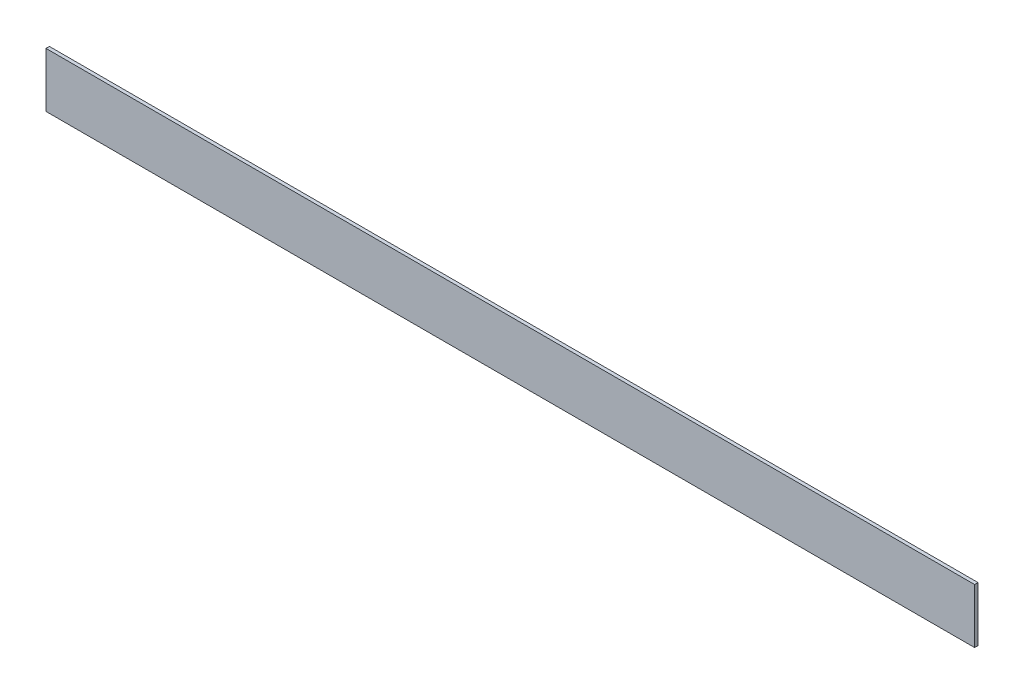
from build123d import *

# Parameters (mm, degrees)
SKETCH1_W           = 863.6
SKETCH1_H           = 50.8
BOSS_EXTRUDE1_DEPTH = 3.175


with BuildPart() as part:
    # Sketch1 → Boss-Extrude1 (new body)
    with BuildSketch(Plane.XY):
        with Locations((-431.8, -25.4)):
            Rectangle(SKETCH1_W, SKETCH1_H)
    extrude(amount=BOSS_EXTRUDE1_DEPTH)


solid = part.part
